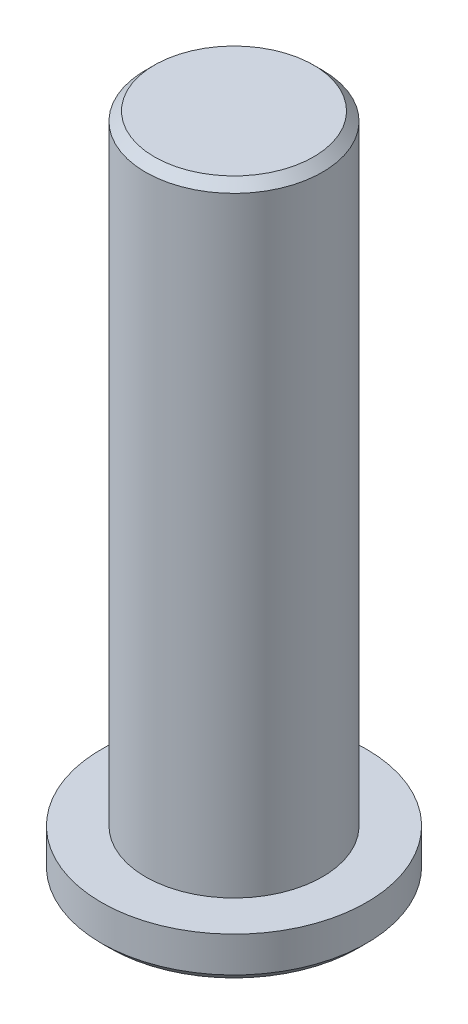
from build123d import *

# Parameters (mm, degrees)
SKETCH_1_R      = 15
EXTRUDE_1_DEPTH = 5
SKETCH_2_R      = 10
EXTRUDE_2_DEPTH = 70
CHAMFER_1_SIZE  = 1


with BuildPart() as part:
    # 草图1 → 凸台-拉伸1 (new body)
    with BuildSketch(Plane(origin=(0, 0, 0), x_dir=(1, 0, 0), z_dir=(0, 1, 0))):
        Circle(SKETCH_1_R)
    extrude(amount=EXTRUDE_1_DEPTH)

    # 草图2 → 凸台-拉伸2 (add)
    with BuildSketch(Plane(origin=(0, 5, 0), x_dir=(1, 0, 0), z_dir=(0, 1, 0))):
        Circle(SKETCH_2_R)
    extrude(amount=EXTRUDE_2_DEPTH)

    # 倒角1
    chamfer_1_edges = [part.edges().sort_by_distance(p)[0] for p in [
        (-15, 0, 0),
        (-10, 75, 0),
    ]]
    chamfer(chamfer_1_edges, length=CHAMFER_1_SIZE)


solid = part.part
